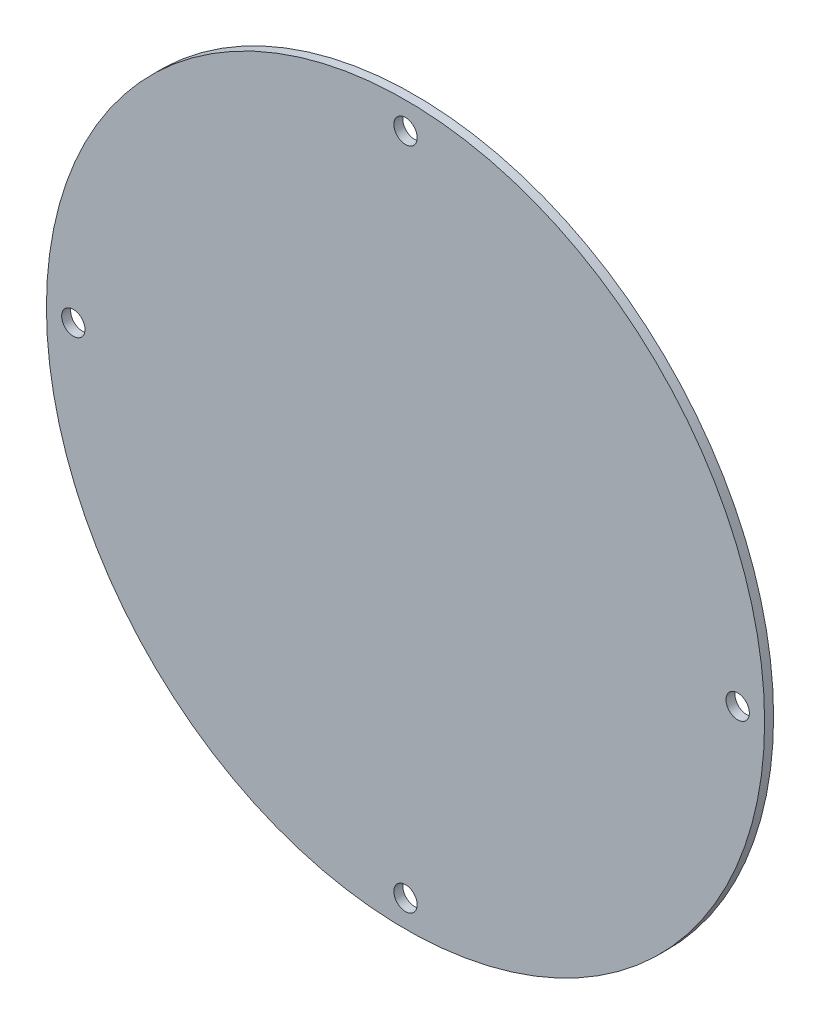
from build123d import *

# Parameters (mm, degrees)
ESQUISSE1_R                  = 40
BOSS_EXTRU_1_DEPTH           = 1
D_GAGEMENT_M21_D             = 2.6
R_P_TITION_CIRCULAIRE1_COUNT = 4


with BuildPart() as part:
    # Esquisse1 → Boss.-Extru.1 (new body)
    with BuildSketch(Plane.XY):
        Circle(ESQUISSE1_R)
    extrude(amount=BOSS_EXTRU_1_DEPTH)

    # Dégagement M21 (through all)
    with Locations(Plane(origin=(0, 0, 0), x_dir=(-1, 0, 0), z_dir=(0, 0, -1))):
        with Locations((0, 37)):
            d_gagement_m21 = Hole(D_GAGEMENT_M21_D / 2)

    # Répétition circulaire1: Dégagement M21 ×4 about axis
    r_p_tition_circulaire1_axis = Axis((0, 0, 0), (0, 0, 1))
    for i in range(1, R_P_TITION_CIRCULAIRE1_COUNT):
        add(d_gagement_m21.rotate(r_p_tition_circulaire1_axis, i * 360 / R_P_TITION_CIRCULAIRE1_COUNT), mode=Mode.SUBTRACT)


solid = part.part
